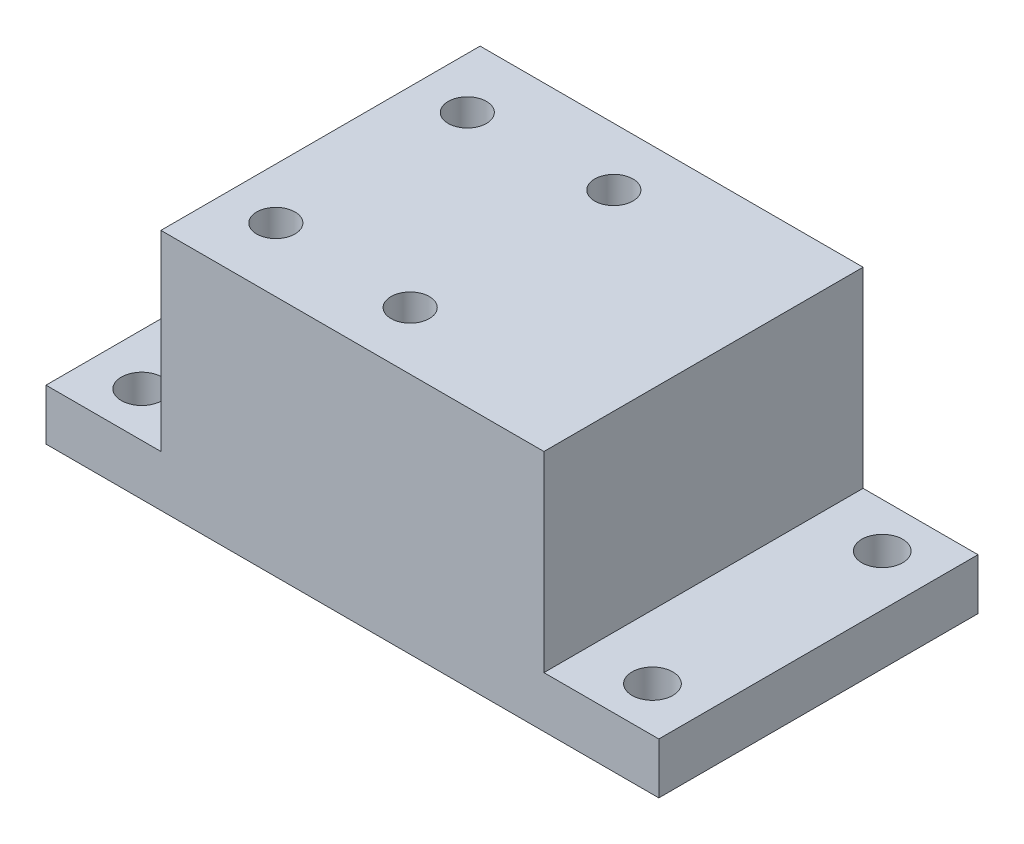
from build123d import *

# Parameters (mm, degrees)
SKETCH1_W           = 48
SKETCH1_H           = 25
BOSS_EXTRUDE1_DEPTH = 4
SKETCH2_W           = 30
SKETCH2_H           = 25
BOSS_EXTRUDE2_DEPTH = 15
SKETCH3_R           = 1.5
CUT_EXTRUDE1_DEPTH  = 20
SKETCH4_R           = 1.6
CUT_EXTRUDE2_DEPTH  = 20


with BuildPart() as part:
    # Sketch1 → Boss-Extrude1 (new body)
    with BuildSketch(Plane(origin=(0, 0, 0), x_dir=(1, 0, 0), z_dir=(0, 1, 0))):
        Rectangle(SKETCH1_W, SKETCH1_H)
    extrude(amount=BOSS_EXTRUDE1_DEPTH)

    # Sketch2 → Boss-Extrude2 (add)
    with BuildSketch(Plane(origin=(0, 4, 0), x_dir=(1, 0, 0), z_dir=(0, 1, 0))):
        Rectangle(SKETCH2_W, SKETCH2_H)
    extrude(amount=BOSS_EXTRUDE2_DEPTH)

    # Sketch3 → Cut-Extrude1 (cut, through all)
    with BuildSketch(Plane(origin=(0, 19, 0), x_dir=(1, 0, 0), z_dir=(0, 1, 0))):
        with Locations(Location((0, 7.975, 0), (0, 0, 270))):  # turned: the seam where the file's is
            Circle(SKETCH3_R)
        with Locations(Location((0, -7.975, 0), (0, 0, 270))):  # turned: the seam where the file's is
            Circle(SKETCH3_R)
        with Locations(Location((-11, 7.5, 0), (0, 0, 270))):  # turned: the seam where the file's is
            Circle(SKETCH3_R)
        with Locations(Location((-11, -7.5, 0), (0, 0, 270))):  # turned: the seam where the file's is
            Circle(SKETCH3_R)
    extrude(amount=-CUT_EXTRUDE1_DEPTH, mode=Mode.SUBTRACT)

    # Sketch4 → Cut-Extrude2 (cut, through all)
    with BuildSketch(Plane.XZ):
        with Locations(Location((-20, 9, 0), (0, 0, 270))):  # turned: the seam where the file's is
            Circle(SKETCH4_R)
        with Locations(Location((20, 9, 0), (0, 0, 270))):  # turned: the seam where the file's is
            Circle(SKETCH4_R)
        with Locations(Location((20, -9, 0), (0, 0, 270))):  # turned: the seam where the file's is
            Circle(SKETCH4_R)
        with Locations(Location((-20, -9, 0), (0, 0, 270))):  # turned: the seam where the file's is
            Circle(SKETCH4_R)
    extrude(amount=-CUT_EXTRUDE2_DEPTH, mode=Mode.SUBTRACT)


solid = part.part
